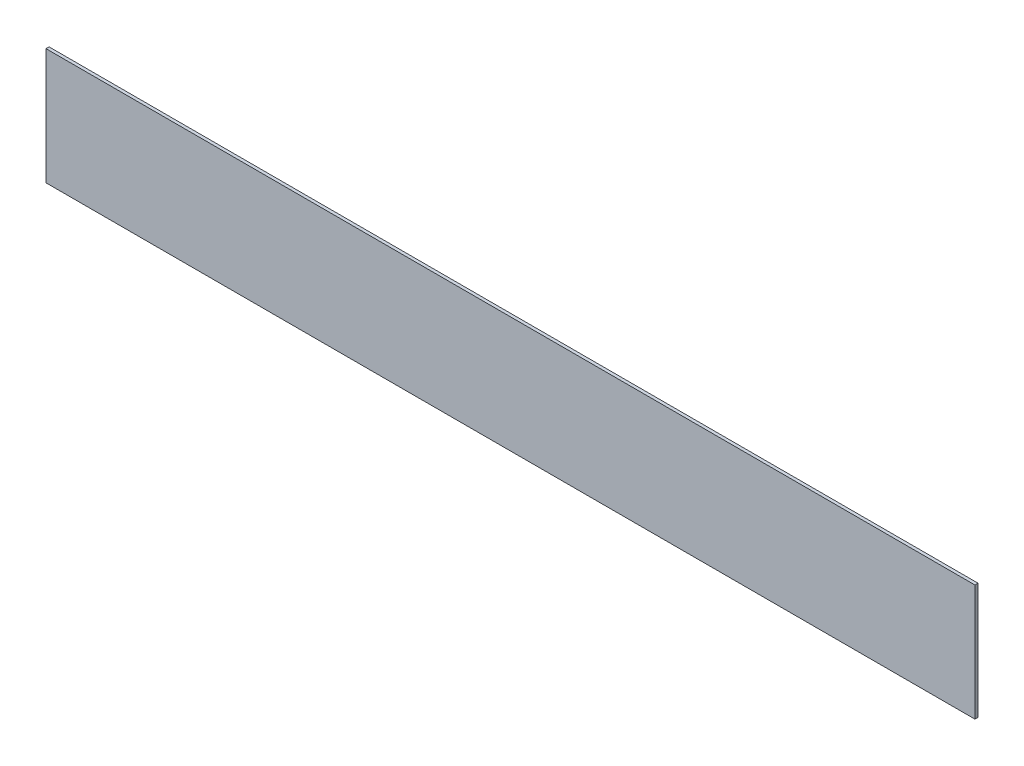
from build123d import *

# Parameters (mm, degrees)
ESBO_O1_W                = 1199
ESBO_O1_H                = 150
RESSALTO_EXTRUS_O1_DEPTH = 4


with BuildPart() as part:
    # Esboço1 → Ressalto-extrusão1 (new body)
    with BuildSketch(Plane.XY):
        Rectangle(ESBO_O1_W, ESBO_O1_H)
    extrude(amount=RESSALTO_EXTRUS_O1_DEPTH)


solid = part.part
